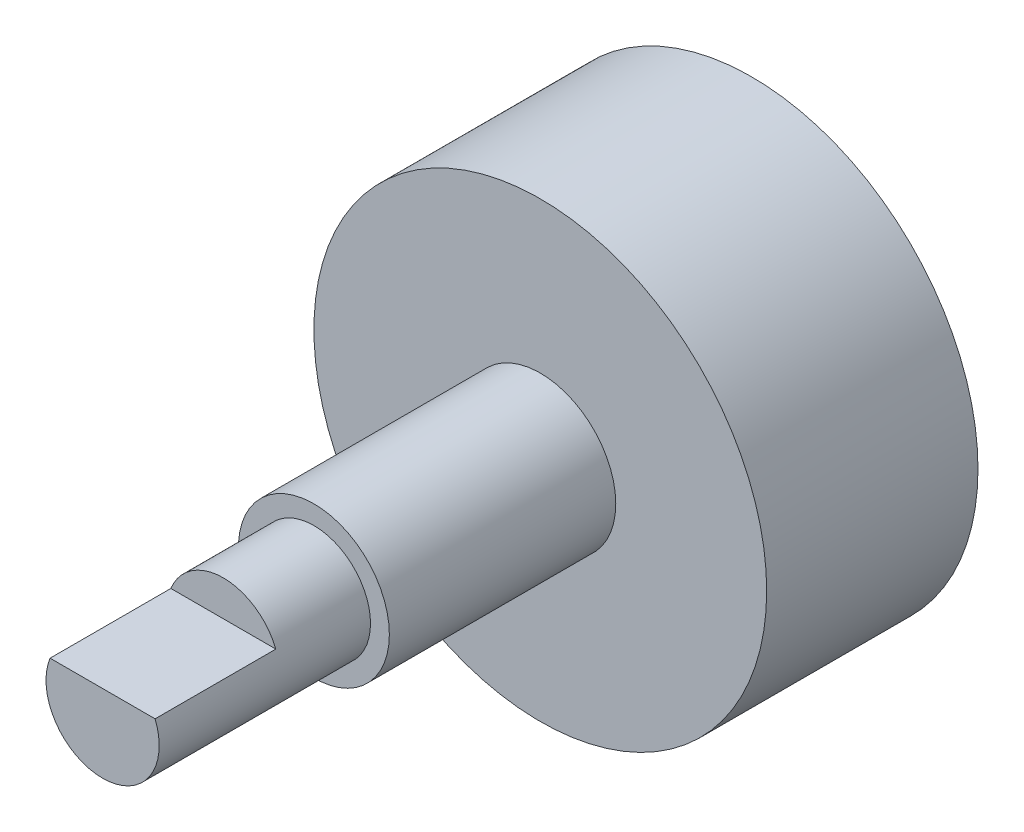
from build123d import *

# Parameters (mm, degrees)
SKETCH1_R           = 9.525
BOSS_EXTRUDE1_DEPTH = 8.89
SKETCH2_R           = 3.175
BOSS_EXTRUDE2_DEPTH = 9.525
SKETCH3_R           = 2.38125
BOSS_EXTRUDE3_DEPTH = 8.89
CUT_EXTRUDE1_DEPTH  = 5.08


with BuildPart() as part:
    # Sketch1 → Boss-Extrude1 (new body)
    with BuildSketch(Plane.XY):
        Circle(SKETCH1_R)
    extrude(amount=-BOSS_EXTRUDE1_DEPTH)

    # Sketch2 → Boss-Extrude2 (add)
    with BuildSketch(Plane.XY):
        Circle(SKETCH2_R)
    extrude(amount=BOSS_EXTRUDE2_DEPTH)

    # Sketch3 → Boss-Extrude3 (add)
    with BuildSketch(Plane.XY.offset(9.525)):
        Circle(SKETCH3_R)
    extrude(amount=BOSS_EXTRUDE3_DEPTH)

    # Sketch4 → Cut-Extrude1 (cut)
    with BuildSketch(Plane.XY.offset(18.415)):
        with BuildLine():
            Line((-4.269996199, 0.889), (4.269996199, 0.889))
            ThreePointArc((4.269996199, 0.889), (0, 5.158996199), (-4.269996199, 0.889))
        make_face()
    extrude(amount=-CUT_EXTRUDE1_DEPTH, mode=Mode.SUBTRACT)


solid = part.part
